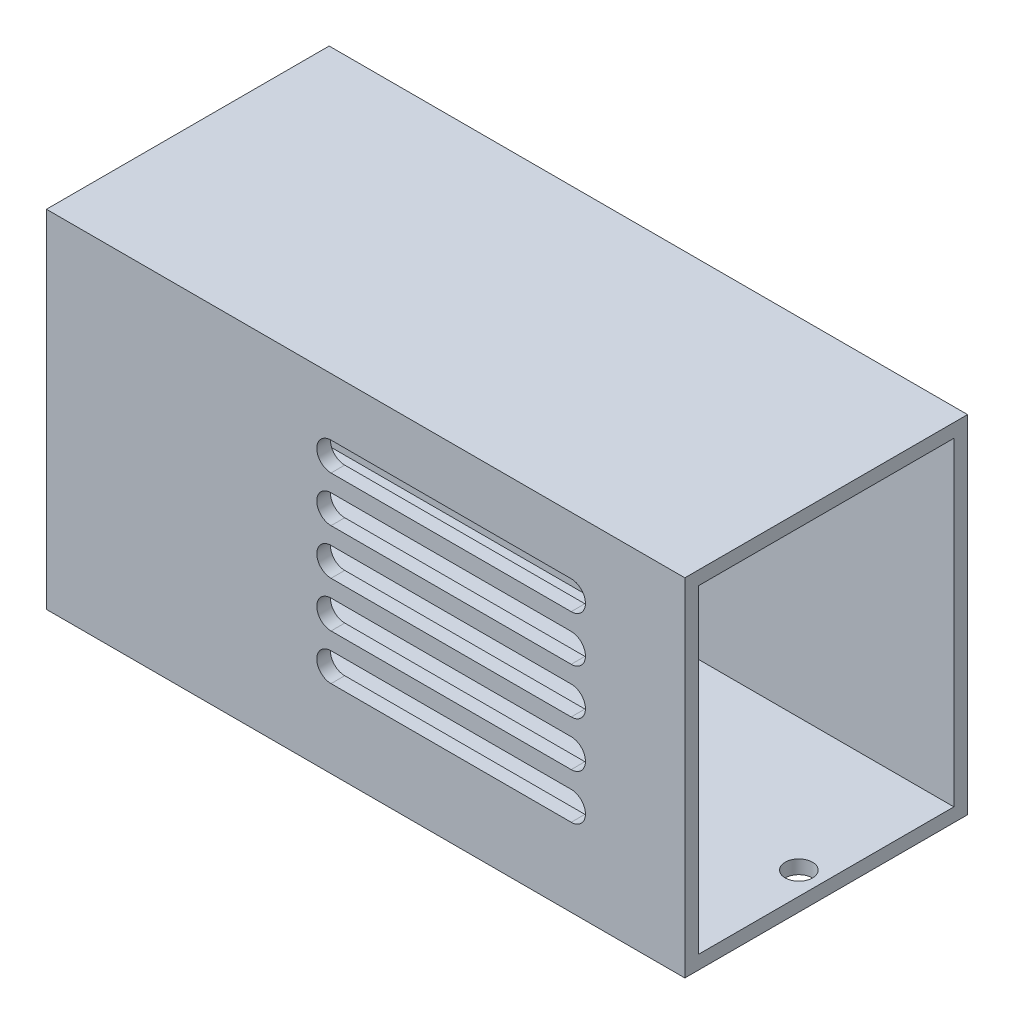
from build123d import *

# Parameters (mm, degrees)
SKETCH_1_W          = 70
SKETCH_1_H          = 38
EXTRUDE_1_DEPTH     = 31
SKETCH_2_W          = 28
SKETCH_2_H          = 35
CUT_EXTRUDE_1_DEPTH = 71
CUT_EXTRUDE_3_DEPTH = 2
SKETCH_5_R          = 1.5
CUT_EXTRUDE_4_DEPTH = 2


with BuildPart() as part:
    # 草图1 → 凸台-拉伸1 (new body)
    with BuildSketch(Plane.XY):
        Rectangle(SKETCH_1_W, SKETCH_1_H)
    extrude(amount=EXTRUDE_1_DEPTH)

    # 草图2 → 切除-拉伸1 (cut, through all)
    with BuildSketch(Plane(origin=(35, 0, 0), x_dir=(0, 0, -1), z_dir=(1, 0, 0))):
        with Locations((-15.5, 0)):
            Rectangle(SKETCH_2_W, SKETCH_2_H)
    extrude(amount=-CUT_EXTRUDE_1_DEPTH, mode=Mode.SUBTRACT)

    # 草图4 → 切除-拉伸3 (cut)
    with BuildSketch(Plane.XY.offset(31)):
        with BuildLine():
            Line((-3.793519022, 12.68225477), (22.537965955, 12.68225477))
            ThreePointArc((22.537965955, 12.68225477), (24.1000032, 11.120217526), (22.537965955, 9.558180281))
            Line((22.537965955, 9.558180281), (-3.793519022, 9.558180281))
            ThreePointArc((-3.793519022, 9.558180281), (-5.355556267, 11.120217526), (-3.793519022, 12.68225477))
        make_face()
        with BuildLine():
            Line((-3.793519022, 4.558180281), (22.537965955, 4.558180281))
            ThreePointArc((22.537965955, 4.558180281), (24.1000032, 6.120217526), (22.537965955, 7.68225477))
            Line((22.537965955, 7.68225477), (-3.793519022, 7.68225477))
            ThreePointArc((-3.793519022, 7.68225477), (-5.355556267, 6.120217526), (-3.793519022, 4.558180281))
        make_face()
        with BuildLine():
            Line((-3.793519022, -0.441819719), (22.537965955, -0.441819719))
            ThreePointArc((22.537965955, -0.441819719), (24.1000032, 1.120217526), (22.537965955, 2.68225477))
            Line((22.537965955, 2.68225477), (-3.793519022, 2.68225477))
            ThreePointArc((-3.793519022, 2.68225477), (-5.355556267, 1.120217526), (-3.793519022, -0.441819719))
        make_face()
        with BuildLine():
            Line((-3.793519022, -5.441819719), (22.537965955, -5.441819719))
            ThreePointArc((22.537965955, -5.441819719), (24.1000032, -3.879782474), (22.537965955, -2.31774523))
            Line((22.537965955, -2.31774523), (-3.793519022, -2.31774523))
            ThreePointArc((-3.793519022, -2.31774523), (-5.355556267, -3.879782474), (-3.793519022, -5.441819719))
        make_face()
        with BuildLine():
            Line((-3.793519022, -10.441819719), (22.537965955, -10.441819719))
            ThreePointArc((22.537965955, -10.441819719), (24.1000032, -8.879782474), (22.537965955, -7.31774523))
            Line((22.537965955, -7.31774523), (-3.793519022, -7.31774523))
            ThreePointArc((-3.793519022, -7.31774523), (-5.355556267, -8.879782474), (-3.793519022, -10.441819719))
        make_face()
    extrude(amount=-CUT_EXTRUDE_3_DEPTH, mode=Mode.SUBTRACT)

    # 草图5 → 切除-拉伸4 (cut)
    with BuildSketch(Plane.XZ.offset(19)):
        with Locations((-32.5, 16)):
            Circle(SKETCH_5_R)
        with Locations((32.5, 16)):
            Circle(SKETCH_5_R)
    extrude(amount=-CUT_EXTRUDE_4_DEPTH, mode=Mode.SUBTRACT)


solid = part.part
